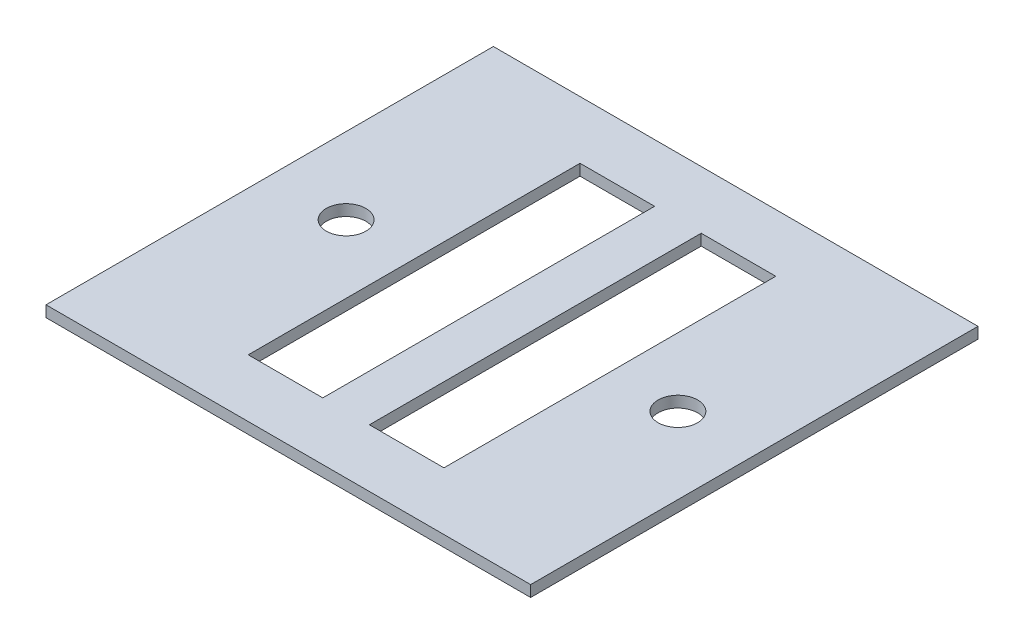
from build123d import *

# Parameters (mm, degrees)
SKETCH1_W           = 130
SKETCH1_H           = 120
BOSS_EXTRUDE1_DEPTH = 3
CUT_EXTRUDE1_START  = -4
SKETCH2_W           = 20
SKETCH2_H           = 89
CUT_EXTRUDE1_DEPTH  = 5
CUT_EXTRUDE2_START  = -4
SKETCH3_R           = 5.3
CUT_EXTRUDE2_DEPTH  = 5


with BuildPart() as part:
    # Sketch1 → Boss-Extrude1 (new body)
    with BuildSketch(Plane(origin=(0, 0, 0), x_dir=(1, 0, 0), z_dir=(0, 1, 0))):
        Rectangle(SKETCH1_W, SKETCH1_H)
    extrude(amount=BOSS_EXTRUDE1_DEPTH)

    # Sketch2 → Cut-Extrude1 (cut)
    with BuildSketch(Plane(origin=(0, 3, 0), x_dir=(1, 0, 0), z_dir=(0, 1, 0)).offset(CUT_EXTRUDE1_START)):
        with Locations((-16.25, 0)):
            Rectangle(SKETCH2_W, SKETCH2_H)
    cut_extrude1 = extrude(amount=CUT_EXTRUDE1_DEPTH, mode=Mode.SUBTRACT)

    # Mirror1: Cut-Extrude1 across plane
    add(cut_extrude1.mirror(Plane(origin=(0, 0, 0), x_dir=(0, 0, 1), z_dir=(1, 0, 0))), mode=Mode.SUBTRACT)

    # Sketch3 → Cut-Extrude2 (cut)
    with BuildSketch(Plane(origin=(0, 3, 0), x_dir=(1, 0, 0), z_dir=(0, 1, 0)).offset(CUT_EXTRUDE2_START)):
        with Locations((44.5, 0)):
            Circle(SKETCH3_R)
    cut_extrude2 = extrude(amount=CUT_EXTRUDE2_DEPTH, mode=Mode.SUBTRACT)

    # Mirror2: Cut-Extrude2 across plane
    add(cut_extrude2.mirror(Plane(origin=(0, 0, 0), x_dir=(0, 0, 1), z_dir=(1, 0, 0))), mode=Mode.SUBTRACT)


solid = part.part
